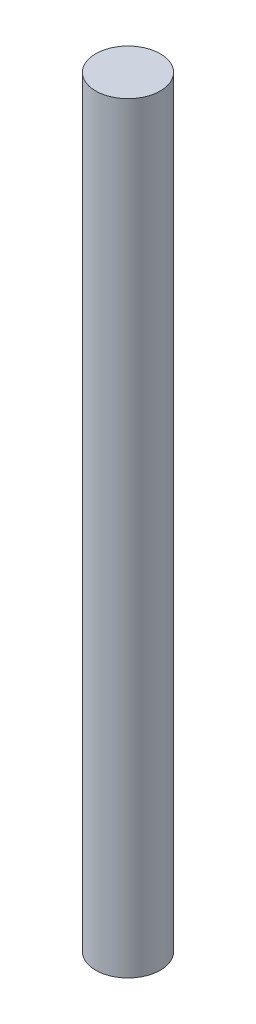
from build123d import *

# Parameters (mm, degrees)
SKETCH1_R                = 2.5
BOSS_EXTRUDE1_DEPTH      = 37
BOSS_EXTRUDE1_DEPTH_BACK = 22


with BuildPart() as part:
    # Sketch1 → Boss-Extrude1 (new body, two sides)
    with BuildSketch(Plane(origin=(0, 0, 0), x_dir=(1, 0, 0), z_dir=(0, 1, 0))) as boss_extrude1_sk:
        Circle(SKETCH1_R)
    extrude(amount=BOSS_EXTRUDE1_DEPTH)
    extrude(boss_extrude1_sk.sketch, amount=-BOSS_EXTRUDE1_DEPTH_BACK)


solid = part.part
